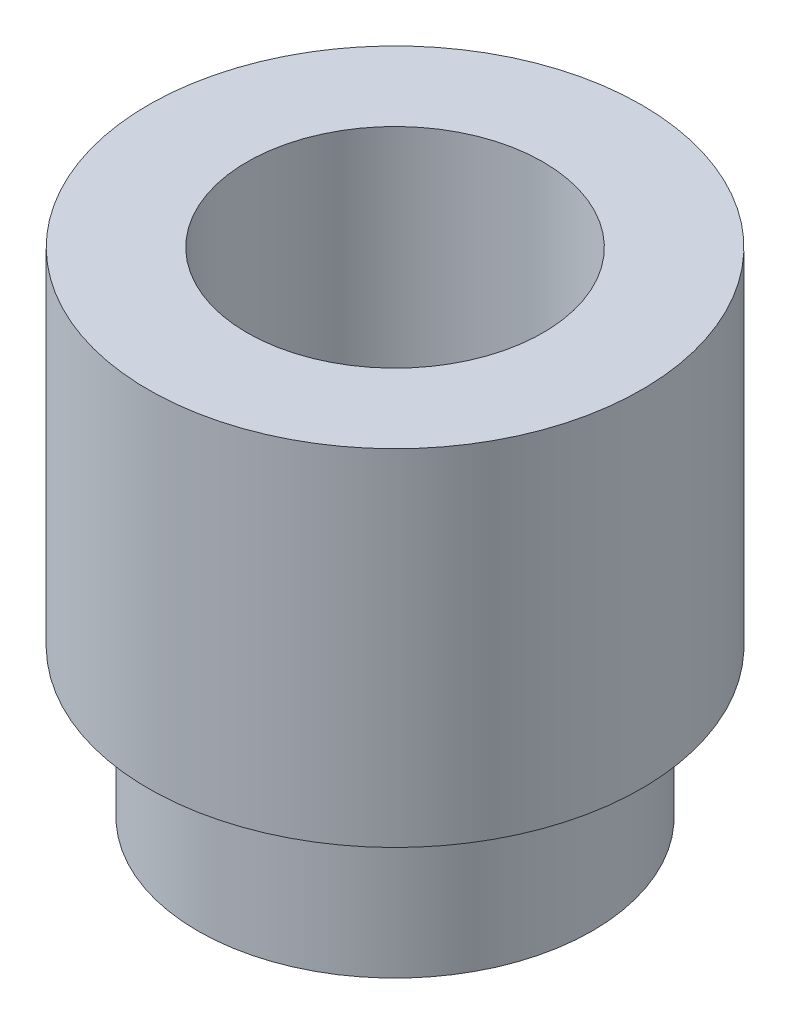
from build123d import *


with BuildPart() as part:
    # Sketch1 → Revolve1 (revolve)
    with BuildSketch(Plane(origin=(0, 0, 0), x_dir=(0, 0, -1), z_dir=(1, 0, 0))):
        Polygon((1.5, 0), (1.5, 5), (2.5, 5), (2.5, 1.5), (2, 1.5), (2, 0), align=None)
    revolve(axis=Axis((0, 0, 0), (0, 1, 0)))


solid = part.part
